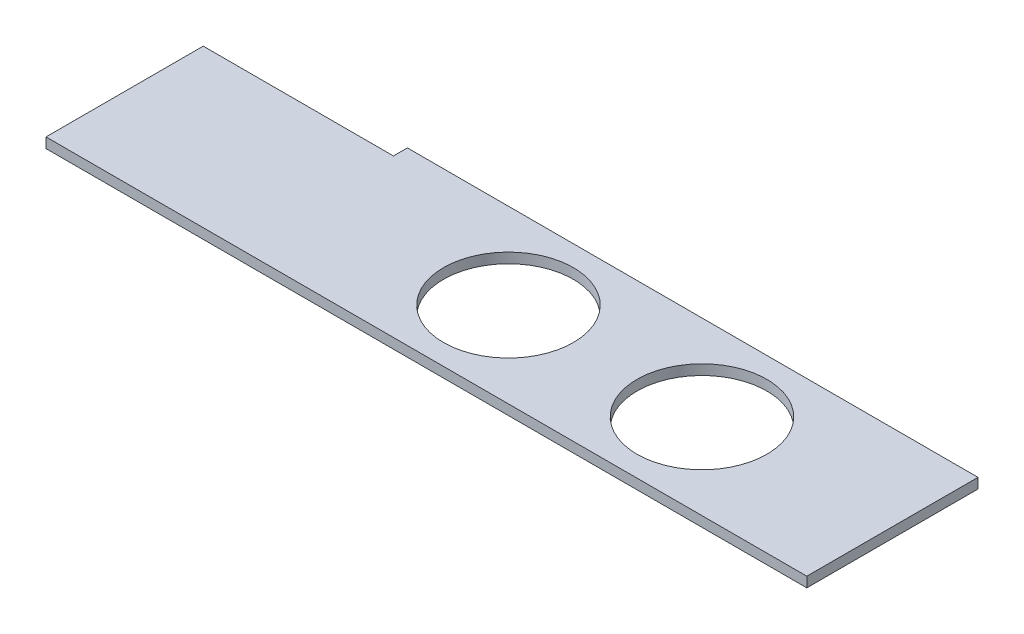
from build123d import *

# Parameters (mm, degrees)
SKETCH2_W           = 600
SKETCH2_H           = 135
BOSS_EXTRUDE1_DEPTH = 8
SKETCH3_R           = 51.2
SKETCH3_W           = 150
SKETCH3_H           = 11
CUT_EXTRUDE1_DEPTH  = 8


with BuildPart() as part:
    # Sketch2 → Boss-Extrude1 (new body)
    with BuildSketch(Plane(origin=(0, 0, 0), x_dir=(1, 0, 0), z_dir=(0, 1, 0))):
        with Locations((300, 67.5)):
            Rectangle(SKETCH2_W, SKETCH2_H)
    extrude(amount=BOSS_EXTRUDE1_DEPTH)

    # Sketch3 → Cut-Extrude1 (cut)
    with BuildSketch(Plane(origin=(0, 8, 0), x_dir=(1, 0, 0), z_dir=(0, 1, 0))):
        with Locations((449.8, 67.5)):
            Circle(SKETCH3_R)
        with Locations((297.2, 67.5)):
            Circle(SKETCH3_R)
        with Locations((75, 129.5)):
            Rectangle(SKETCH3_W, SKETCH3_H)
    extrude(amount=-CUT_EXTRUDE1_DEPTH, mode=Mode.SUBTRACT)


solid = part.part
